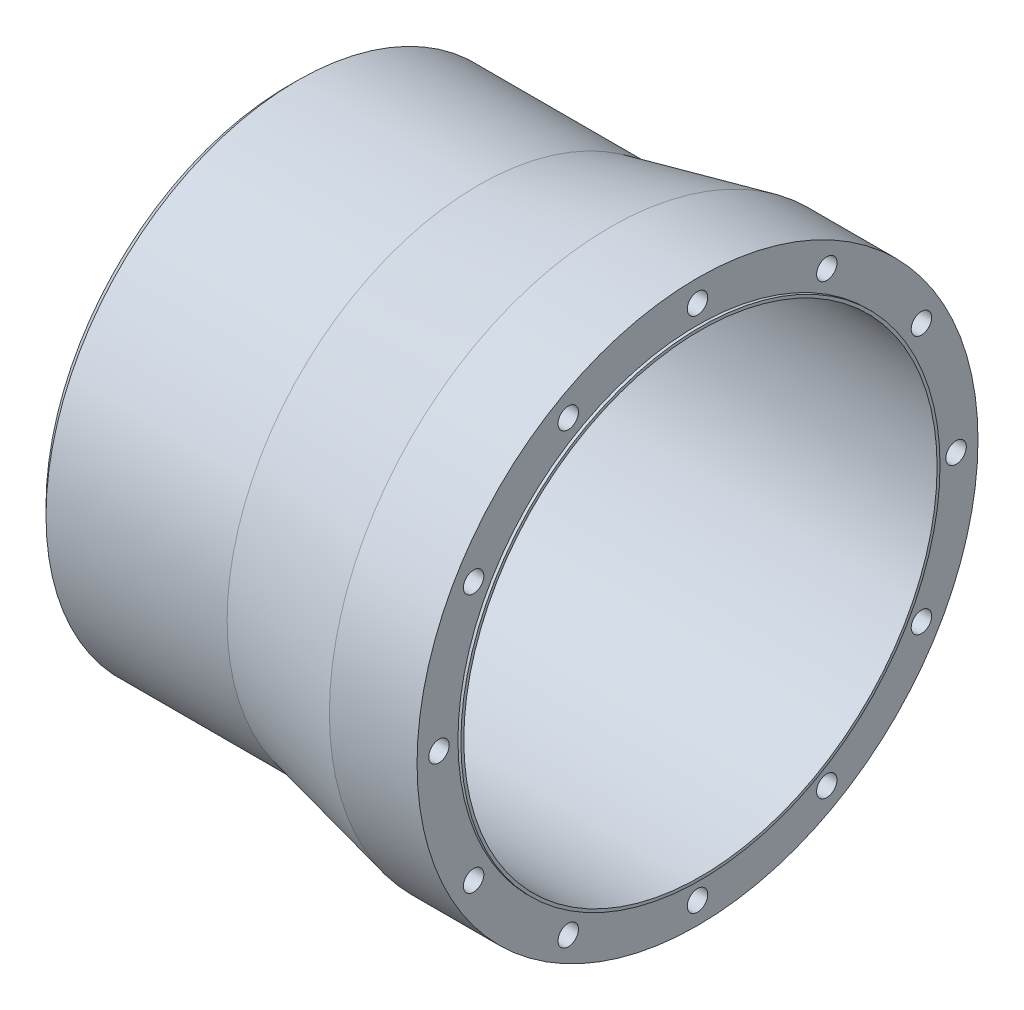
from build123d import *

# Parameters (mm, degrees)
CHAMFER_2_SIZE      = 3
SKETCH_4_R          = 3.5
CUT_EXTRUDE_1_DEPTH = 10
SKETCH_5_R          = 82
SKETCH_5_R_2        = 81
EXTRUDE_1_DEPTH     = 1


with BuildPart() as part:
    # 草图2 → 旋转1 (revolve)
    with BuildSketch(Plane.XY, mode=Mode.PRIVATE) as revolve_1_sk:
        Polygon((10, 81), (150, 81), (150, 86), (150, 96), (120, 96), (75, 86), (10, 86), align=None)
    revolve(revolve_1_sk.sketch.rotate(Axis((0, 0, 0), (1, 0, 0)), 90), axis=Axis((0, 0, 0), (1, 0, 0)))

    # 倒角2
    chamfer_2_edges = [part.edges().sort_by_distance(p)[0] for p in [
        (10, 0, -86),
    ]]
    chamfer(chamfer_2_edges, length=CHAMFER_2_SIZE)

    # 草图4 → 切除-拉伸1 (cut)
    with BuildSketch(Plane(origin=(150, 0, 0), x_dir=(0, 0, -1), z_dir=(1, 0, 0))):
        with Locations((44.25, 76.643248235)):
            Circle(SKETCH_4_R)
        with Locations((0, 88.5)):
            Circle(SKETCH_4_R)
        with Locations((76.643248235, 44.25)):
            Circle(SKETCH_4_R)
        with Locations((88.5, 0)):
            Circle(SKETCH_4_R)
        with Locations((76.643248235, -44.25)):
            Circle(SKETCH_4_R)
        with Locations((44.25, -76.643248235)):
            Circle(SKETCH_4_R)
        with Locations((0, -88.5)):
            Circle(SKETCH_4_R)
        with Locations((-44.25, -76.643248235)):
            Circle(SKETCH_4_R)
        with Locations((-76.643248235, -44.25)):
            Circle(SKETCH_4_R)
        with Locations((-88.5, 0)):
            Circle(SKETCH_4_R)
        with Locations((-76.643248235, 44.25)):
            Circle(SKETCH_4_R)
        with Locations((-44.25, 76.643248235)):
            Circle(SKETCH_4_R)
    extrude(amount=-CUT_EXTRUDE_1_DEPTH, mode=Mode.SUBTRACT)

    # 草图5 → 凸台-拉伸1 (add)
    with BuildSketch(Plane(origin=(150, 0, 0), x_dir=(0, 0, -1), z_dir=(1, 0, 0))):
        with Locations(Location((0, 0, 0), (0, 0, 180))):
            Circle(SKETCH_5_R)
        with Locations(Location((0, 0, 0), (0, 0, 180))):
            Circle(SKETCH_5_R_2, mode=Mode.SUBTRACT)
    extrude(amount=EXTRUDE_1_DEPTH)


solid = part.part
